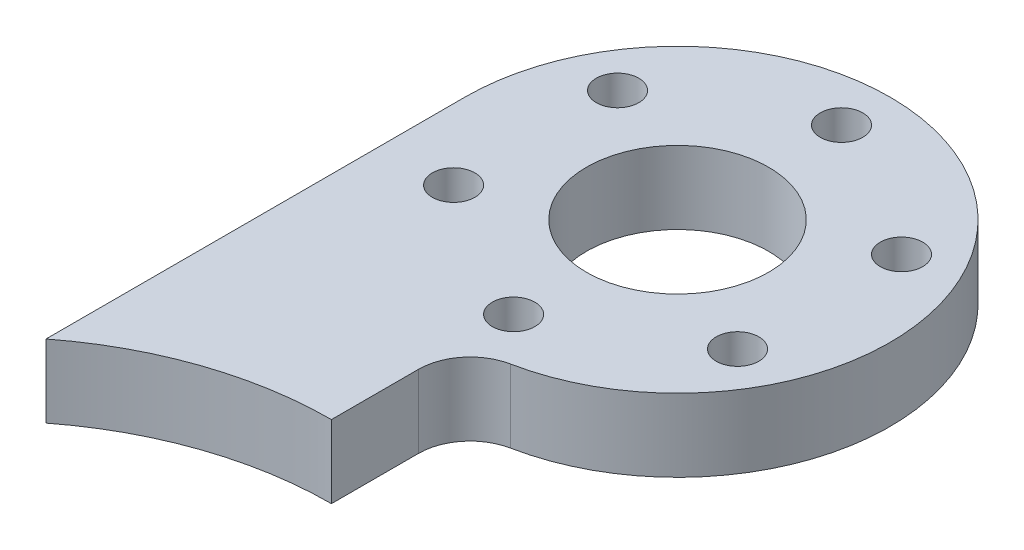
from build123d import *

# Parameters (mm, degrees)
SKETCH_1_R          = 1.75
EXTRUDE_1_DEPTH     = 6
FILLET_2_R          = 4.25
SKETCH_2_R          = 7.5
CUT_EXTRUDE_1_DEPTH = 10


with BuildPart() as part:
    # 草图1 → 凸台-拉伸1 (new body)
    with BuildSketch(Plane(origin=(0, 0, 0), x_dir=(1, 0, 0), z_dir=(0, 1, 0))):
        with BuildLine():
            Line((-17.5, -34.505556242), (-17.5, 0))
            ThreePointArc((-17.5, 0), (0, 17.5), (17.5, 0))
            ThreePointArc((17.5, 0), (12.374368671, -12.374368671), (0, -17.5))
            Line((0, -17.5), (0, -28.5))
            ThreePointArc((0, -28.5), (-9.250901385, -30.043167405), (-17.5, -34.505556242))
        make_face()
        with Locations((0, 13.5)):
            Circle(SKETCH_1_R, mode=Mode.SUBTRACT)
        with Locations((11.691342951, 6.75)):
            Circle(SKETCH_1_R, mode=Mode.SUBTRACT)
        with Locations((11.691342951, -6.75)):
            Circle(SKETCH_1_R, mode=Mode.SUBTRACT)
        with Locations((0, -13.5)):
            Circle(SKETCH_1_R, mode=Mode.SUBTRACT)
        with Locations((-11.691342951, -6.75)):
            Circle(SKETCH_1_R, mode=Mode.SUBTRACT)
        with Locations((-11.691342951, 6.75)):
            Circle(SKETCH_1_R, mode=Mode.SUBTRACT)
    extrude(amount=EXTRUDE_1_DEPTH)

    # 圆角2
    fillet_2_edges = [part.edges().sort_by_distance(p)[0] for p in [
        (0, 3, 17.5),
    ]]
    fillet(fillet_2_edges, radius=FILLET_2_R)

    # 草图2 → 切除-拉伸1 (cut)
    with BuildSketch(Plane(origin=(0, 6, 0), x_dir=(1, 0, 0), z_dir=(0, 1, 0))):
        Circle(SKETCH_2_R)
    extrude(amount=-CUT_EXTRUDE_1_DEPTH, mode=Mode.SUBTRACT)


solid = part.part
